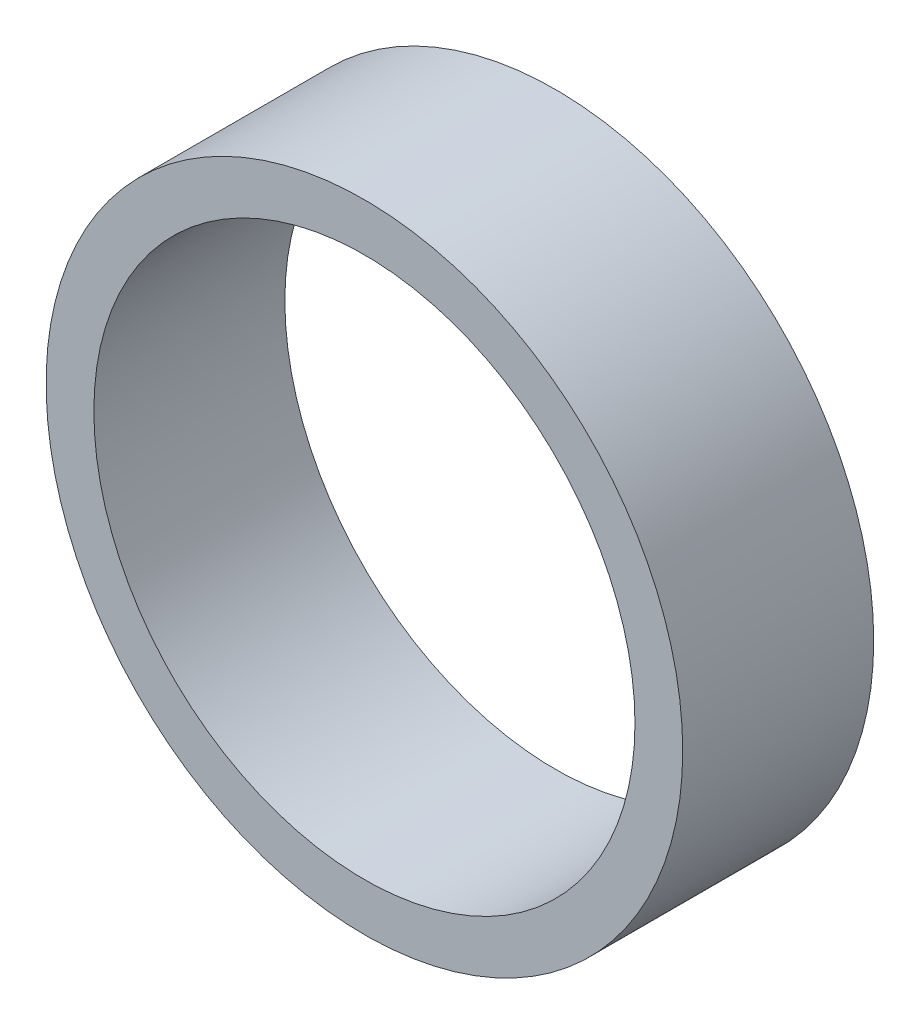
from build123d import *

# Parameters (mm, degrees)
SKETCH1_R           = 10
SKETCH1_R_2         = 8.5
BOSS_EXTRUDE1_DEPTH = 6


with BuildPart() as part:
    # Sketch1 → Boss-Extrude1 (new body)
    with BuildSketch(Plane.XY):
        Circle(SKETCH1_R)
        Circle(SKETCH1_R_2, mode=Mode.SUBTRACT)
    extrude(amount=BOSS_EXTRUDE1_DEPTH)


solid = part.part
